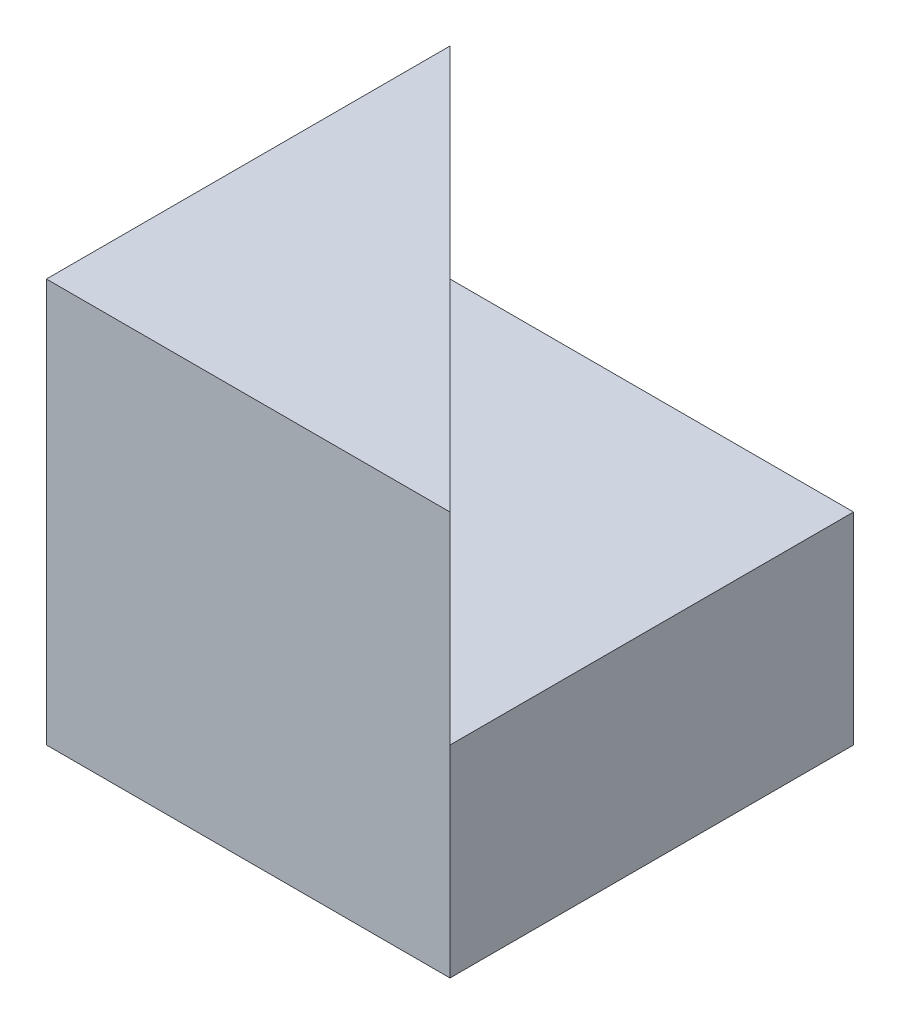
from build123d import *

# Parameters (mm, degrees)
SKETCH1_W           = 40
SKETCH1_H           = 40
BOSS_EXTRUDE1_DEPTH = 40
CUT_EXTRUDE1_DEPTH  = 20


with BuildPart() as part:
    # Sketch1 → Boss-Extrude1 (new body)
    with BuildSketch(Plane.XY):
        with Locations((20, 20)):
            Rectangle(SKETCH1_W, SKETCH1_H)
    extrude(amount=BOSS_EXTRUDE1_DEPTH)

    # Sketch2 → Cut-Extrude1 (cut)
    with BuildSketch(Plane(origin=(0, 40, 0), x_dir=(1, 0, 0), z_dir=(0, 1, 0))):
        Polygon((0, 0), (40, -40), (40, 0), align=None)
    extrude(amount=-CUT_EXTRUDE1_DEPTH, mode=Mode.SUBTRACT)


solid = part.part
